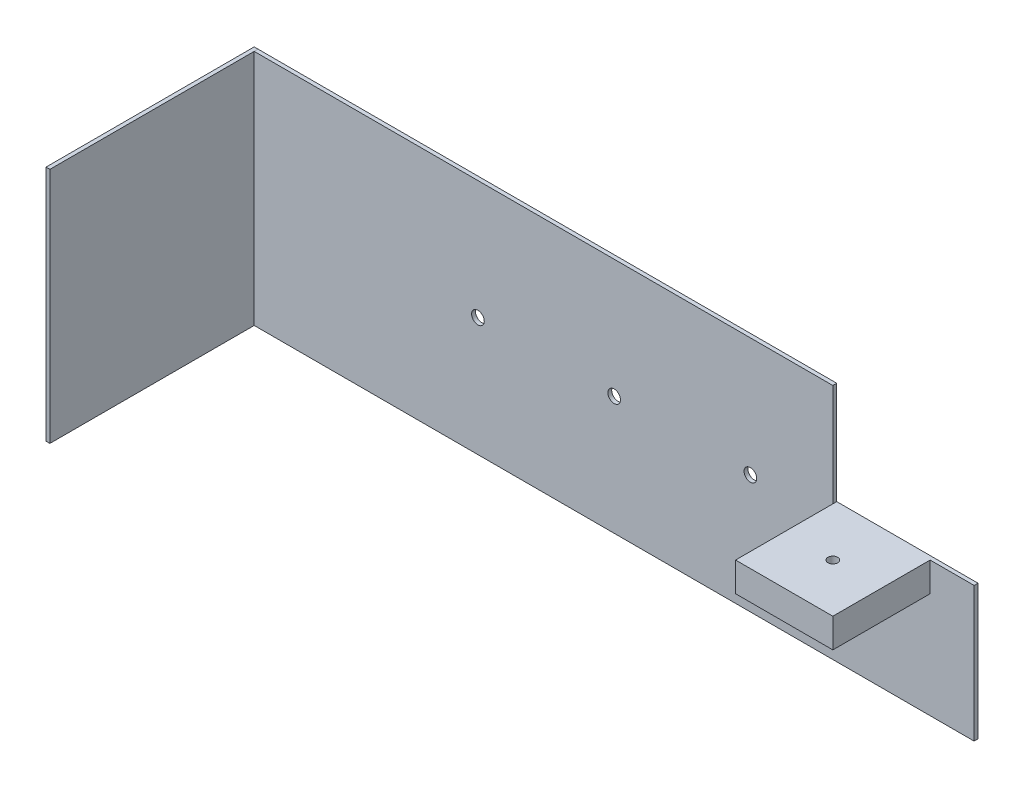
from build123d import *

# Parameters (mm, degrees)
SKETCH_1_W           = 370
SKETCH_1_H           = 122
EXTRUDE_1_DEPTH      = 2
SKETCH_2_W           = 2
SKETCH_2_H           = 122
EXTRUDE_2_DEPTH      = 105
EXTRUDE_2_DEPTH_BACK = 2
SKETCH_3_W           = 50
SKETCH_3_H           = 15
EXTRUDE_3_DEPTH      = 50
SKETCH_5_W           = 2.5
SKETCH_5_H           = 15.001
SKETCH_6_W           = 72.6
SKETCH_6_H           = 52.7
CUT_EXTRUDE_1_DEPTH  = 2
SKETCH_7_R           = 3.25
CUT_EXTRUDE_2_DEPTH  = 2


with BuildPart() as part:
    # 草图1 → 凸台-拉伸1 (new body)
    with BuildSketch(Plane.XY):
        Rectangle(SKETCH_1_W, SKETCH_1_H)
    extrude(amount=EXTRUDE_1_DEPTH)

    # 草图3 → 凸台-拉伸3 (add)
    with BuildSketch(Plane.XY.offset(2)):
        with Locations((137.4, 0.8)):
            Rectangle(SKETCH_3_W, SKETCH_3_H)
    extrude(amount=EXTRUDE_3_DEPTH)

    # 草图5 → M6 螺纹孔1 (revolve, cut)
    with BuildSketch(Plane(origin=(137.4, 8.3, 27), x_dir=(0, 0, 1), z_dir=(1, 0, 0))):
        with Locations((1.25, 7.5005)):
            Rectangle(SKETCH_5_W, SKETCH_5_H)
    revolve(axis=Axis((137.4, 14.65, 27), (0, -1, 0)), mode=Mode.SUBTRACT)

    # 草图6 → 切除-拉伸1 (cut)
    with BuildSketch(Plane.XY.offset(2)):
        with Locations((148.7, 34.65)):
            Rectangle(SKETCH_6_W, SKETCH_6_H)
    extrude(amount=-CUT_EXTRUDE_1_DEPTH, mode=Mode.SUBTRACT)

    # 草图7 → 切除-拉伸2 (cut)
    with BuildSketch(Plane.XY.offset(2)):
        with Locations((-70, 0)):
            Circle(SKETCH_7_R)
        Circle(SKETCH_7_R)
        with Locations((70, 0)):
            Circle(SKETCH_7_R)
    extrude(amount=-CUT_EXTRUDE_2_DEPTH, mode=Mode.SUBTRACT)


with BuildPart() as body_2:
    # 草图2 → 凸台-拉伸2 (new body, two sides)
    with BuildSketch(Plane.XY.offset(2)) as extrude_2_sk:
        with Locations((-186, 0)):
            Rectangle(SKETCH_2_W, SKETCH_2_H)
    extrude(amount=EXTRUDE_2_DEPTH)
    extrude(extrude_2_sk.sketch, amount=-EXTRUDE_2_DEPTH_BACK)


solid = Compound([part.part, body_2.part])
